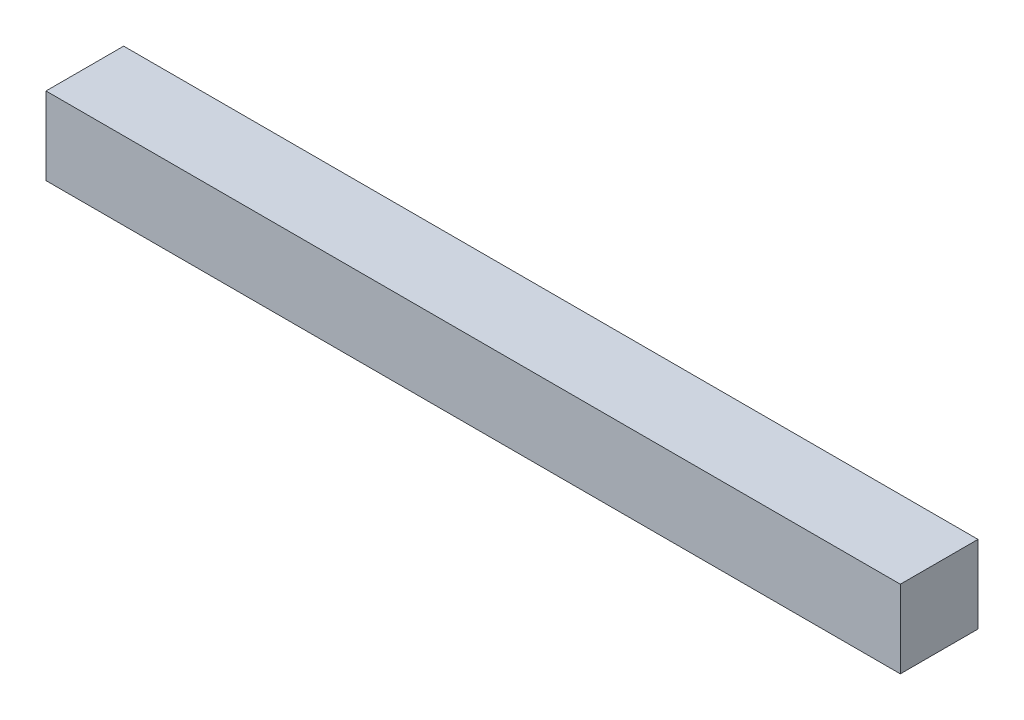
from build123d import *

# Parameters (mm, degrees)
SKETCH1_W           = 30
SKETCH1_H           = 30
BOSS_EXTRUDE1_DEPTH = 165


with BuildPart() as part:
    # Sketch1 → Boss-Extrude1 (new body, symmetric)
    with BuildSketch(Plane(origin=(0, 0, 0), x_dir=(0, 0, -1), z_dir=(1, 0, 0))):
        Rectangle(SKETCH1_W, SKETCH1_H)
    extrude(amount=BOSS_EXTRUDE1_DEPTH, both=True)


solid = part.part
